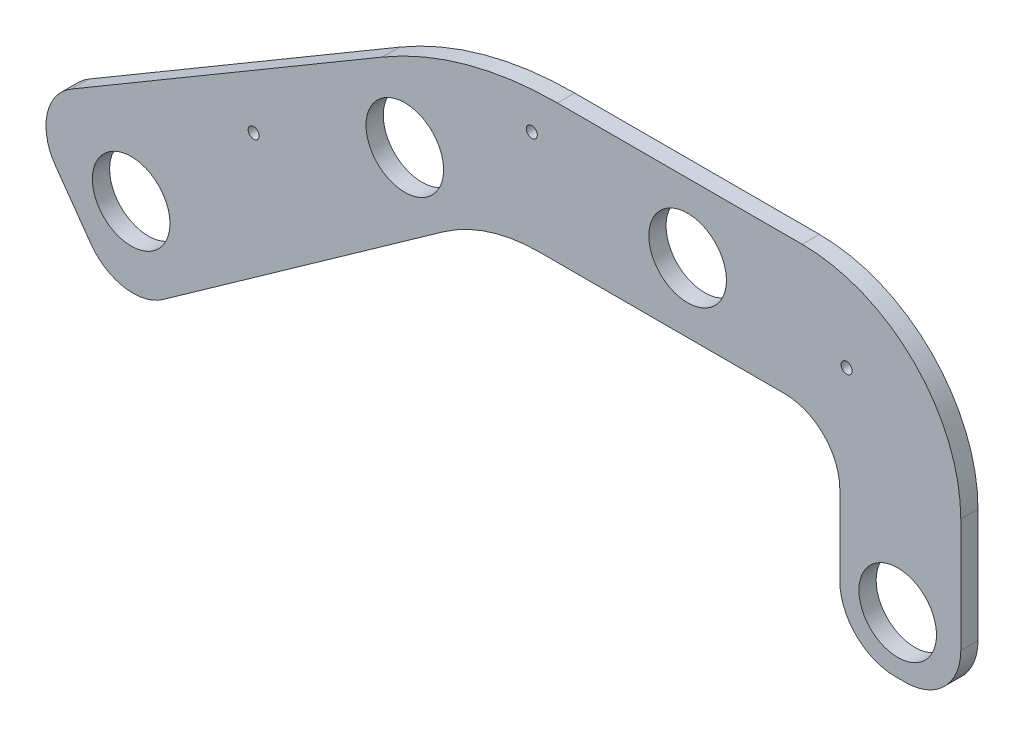
from build123d import *

# Parameters (mm, degrees)
BOSS_EXTRUDE1_DEPTH = 3.175
FILLET4_R           = 127
FILLET8_R           = 6.35
SKETCH4_R           = 14.2875
SKETCH4_R_2         = 2.032
CUT_EXTRUDE1_DEPTH  = 18.415
FILLET20_R          = 33.02
BOSS_EXTRUDE3_DEPTH = 6.35
FILLET23_R          = 127
FILLET24_R          = 19.05
FILLET25_R          = 19.05
SKETCH4_2_R         = 14.2875
SKETCH4_2_R_2       = 2.032
CUT_EXTRUDE2_DEPTH  = 6.35
FILLET27_R          = 60.96
FILLET28_R          = 20.32
FILLET29_R          = 20.32
FILLET30_R          = 20.32
FILLET31_R          = 58.42


with BuildPart() as part:
    # Sketch1 → Boss-Extrude1 (new body)
    with BuildSketch(Plane.XY):
        Polygon((0, 0), (-134.680588616, -95.49423569), (-170.699937974, -44.69423569), (-8.460282393, 50.869520386), (174.726114012, 50.869520386), (174.726114012, -31.75), (174.726114012, -69.85), (130.175, -69.85), (130.175, 0), align=None)
    extrude(amount=BOSS_EXTRUDE1_DEPTH)

    # Fillet4
    fillet4_edges = [part.edges().sort_by_distance(p)[0] for p in [
        (-8.460282393, 50.869520386, 1.5875),
    ]]
    fillet(fillet4_edges, radius=FILLET4_R)

    # Fillet8
    fillet8_edges = [part.edges().sort_by_distance(p)[0] for p in [
        (174.726114012, 50.869520386, 1.5875),
    ]]
    fillet(fillet8_edges, radius=FILLET8_R)

    # Sketch4 → Cut-Extrude1 (cut)
    with BuildSketch(Plane(origin=(0, 0, 0), x_dir=(-1, 0, 0), z_dir=(0, 0, -1))):
        with Locations((-151.503295524, -49.024477041)):
            Circle(SKETCH4_R)
        with Locations((130.843837195, -58.984690885)):
            Circle(SKETCH4_R)
        with Locations((30.055030467, 8.563007376)):
            Circle(SKETCH4_R)
        with Locations((-74.112358802, 25.4)):
            Circle(SKETCH4_R)
        with Locations((85.728358398, -14.612108422)):
            Circle(SKETCH4_R_2)
        with Locations((-132.677584994, 19.676786483)):
            Circle(SKETCH4_R_2)
        with Locations((-16.730295544, 36.917955745)):
            Circle(SKETCH4_R_2)
    extrude(amount=-CUT_EXTRUDE1_DEPTH, mode=Mode.SUBTRACT)

    # Fillet20
    fillet20_edges = [part.edges().sort_by_distance(p)[0] for p in [
        (-134.680588616, -95.49423569, 1.5875),
    ]]
    fillet(fillet20_edges, radius=FILLET20_R)

    # Sketch1_3 → Boss-Extrude3 (add)
    with BuildSketch(Plane.XY):
        Polygon((0, 0), (-134.680588616, -95.49423569), (-170.699937974, -44.69423569), (-8.460282393, 50.869520386), (174.726114012, 50.869520386), (174.726114012, -31.75), (174.726114012, -69.85), (130.175, -69.85), (130.175, 0), align=None)
    extrude(amount=BOSS_EXTRUDE3_DEPTH)

    # Fillet23
    fillet23_edges = [part.edges().sort_by_distance(p)[0] for p in [
        (-8.460282393, 50.869520386, 3.175),
    ]]
    fillet(fillet23_edges, radius=FILLET23_R)

    # Fillet24
    fillet24_edges = [part.edges().sort_by_distance(p)[0] for p in [
        (-170.699937974, -44.69423569, 3.175),
    ]]
    fillet(fillet24_edges, radius=FILLET24_R)

    # Fillet25
    fillet25_edges = [part.edges().sort_by_distance(p)[0] for p in [
        (-134.680588616, -95.49423569, 3.175),
    ]]
    fillet(fillet25_edges, radius=FILLET25_R)

    # Sketch4_2 → Cut-Extrude2 (cut)
    with BuildSketch(Plane(origin=(0, 0, 0), x_dir=(-1, 0, 0), z_dir=(0, 0, -1))):
        with Locations((-151.503295524, -49.024477041)):
            Circle(SKETCH4_2_R)
        with Locations((130.843837195, -58.984690885)):
            Circle(SKETCH4_2_R)
        with Locations((30.055030467, 8.563007376)):
            Circle(SKETCH4_2_R)
        with Locations((-74.112358802, 25.4)):
            Circle(SKETCH4_2_R)
        with Locations((85.728358398, -14.612108422)):
            Circle(SKETCH4_2_R_2)
        with Locations((-132.677584994, 19.676786483)):
            Circle(SKETCH4_2_R_2)
        with Locations((-16.730295544, 36.917955745)):
            Circle(SKETCH4_2_R_2)
    extrude(amount=-CUT_EXTRUDE2_DEPTH, mode=Mode.SUBTRACT)

    # Fillet27
    fillet27_edges = [part.edges().sort_by_distance(p)[0] for p in [
        (0, 0, 3.175),
    ]]
    fillet(fillet27_edges, radius=FILLET27_R)

    # Fillet28
    fillet28_edges = [part.edges().sort_by_distance(p)[0] for p in [
        (130.175, 0, 3.175),
    ]]
    fillet(fillet28_edges, radius=FILLET28_R)

    # Fillet29
    fillet29_edges = [part.edges().sort_by_distance(p)[0] for p in [
        (130.175, -69.85, 3.175),
    ]]
    fillet(fillet29_edges, radius=FILLET29_R)

    # Fillet30
    fillet30_edges = [part.edges().sort_by_distance(p)[0] for p in [
        (174.726114012, -69.85, 3.175),
    ]]
    fillet(fillet30_edges, radius=FILLET30_R)

    # Fillet31
    fillet31_edges = [part.edges().sort_by_distance(p)[0] for p in [
        (174.726114012, 50.869520386, 3.175),
    ]]
    fillet(fillet31_edges, radius=FILLET31_R)


solid = part.part
